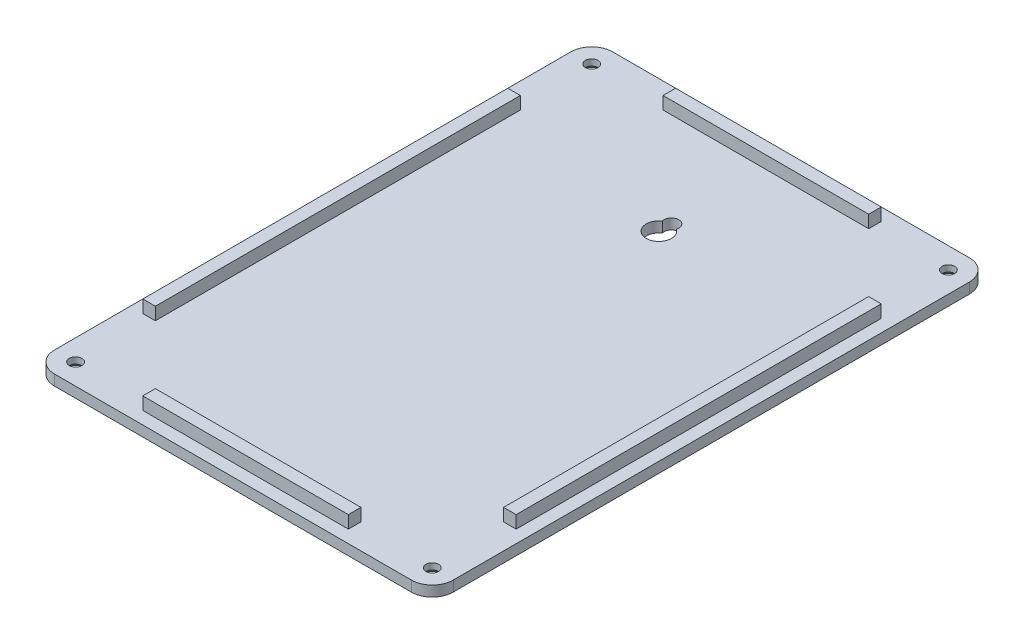
from build123d import *

# Parameters (mm, degrees)
EXTRUDE_1_DEPTH     = 2.5
SKETCH_2_R          = 1.5
CUT_EXTRUDE_1_DEPTH = 11
SKETCH_3_W          = 49
SKETCH_3_H          = 3
SKETCH_3_W_2        = 3
SKETCH_3_H_2        = 87
EXTRUDE_2_DEPTH     = 3
CUT_EXTRUDE_2_DEPTH = 6
CHAMFER_1_SIZE      = 1


with BuildPart() as part:
    # Эскиз1 → Бобышка-Вытянуть1 (new body)
    with BuildSketch(Plane(origin=(0, 0, 0), x_dir=(1, 0, 0), z_dir=(0, 1, 0))):
        with BuildLine():
            Line((-42.5, -66.5), (42.5, -66.5))
            ThreePointArc((42.5, -66.5), (46.035533906, -65.035533906), (47.5, -61.5))
            Line((47.5, -61.5), (47.5, 61.5))
            ThreePointArc((47.5, 61.5), (46.035533906, 65.035533906), (42.5, 66.5))
            Line((42.5, 66.5), (-42.5, 66.5))
            ThreePointArc((-42.5, 66.5), (-46.035533906, 65.035533906), (-47.5, 61.5))
            Line((-47.5, 61.5), (-47.5, -61.5))
            ThreePointArc((-47.5, -61.5), (-46.035533906, -65.035533906), (-42.5, -66.5))
        make_face()
    extrude(amount=EXTRUDE_1_DEPTH)

    # Эскиз2 → Вырез-Вытянуть1 (cut)
    with BuildSketch(Plane(origin=(0, 2.5, 0), x_dir=(1, 0, 0), z_dir=(0, 1, 0))):
        with Locations((-42.5, 61.5)):
            Circle(SKETCH_2_R)
        with Locations((42.5, 61.5)):
            Circle(SKETCH_2_R)
        with Locations((42.5, -61.5)):
            Circle(SKETCH_2_R)
        with Locations((-42.5, -61.5)):
            Circle(SKETCH_2_R)
    extrude(amount=-CUT_EXTRUDE_1_DEPTH, mode=Mode.SUBTRACT)

    # Эскиз3 → Бобышка-Вытянуть2 (add)
    with BuildSketch(Plane(origin=(0, 2.5, 0), x_dir=(1, 0, 0), z_dir=(0, 1, 0))):
        with Locations((0, 62)):
            Rectangle(SKETCH_3_W, SKETCH_3_H)
        with Locations((0, -62)):
            Rectangle(SKETCH_3_W, SKETCH_3_H)
        with Locations((-43, 0)):
            Rectangle(SKETCH_3_W_2, SKETCH_3_H_2)
        with Locations((43, 0)):
            Rectangle(SKETCH_3_W_2, SKETCH_3_H_2)
    extrude(amount=EXTRUDE_2_DEPTH)

    # Эскиз4 → Вырез-Вытянуть2 (cut)
    with BuildSketch(Plane(origin=(0, 2.5, 0), x_dir=(1, 0, 0), z_dir=(0, 1, 0))):
        with BuildLine():
            ThreePointArc((-1.673910041, 37.489583333), (0, 39.75), (1.673910041, 37.489583333))
            ThreePointArc((1.673910041, 37.489583333), (0, 32), (-1.673910041, 37.489583333))
        make_face()
    extrude(amount=-CUT_EXTRUDE_2_DEPTH, mode=Mode.SUBTRACT)

    # Фаска1
    chamfer_1_edges = [part.edges().sort_by_distance(p)[0] for p in [
        (-44, 0, 61.5),
        (41, 0, 61.5),
        (41, 0, -61.5),
        (-44, 0, -61.5),
    ]]
    chamfer(chamfer_1_edges, length=CHAMFER_1_SIZE)


solid = part.part
